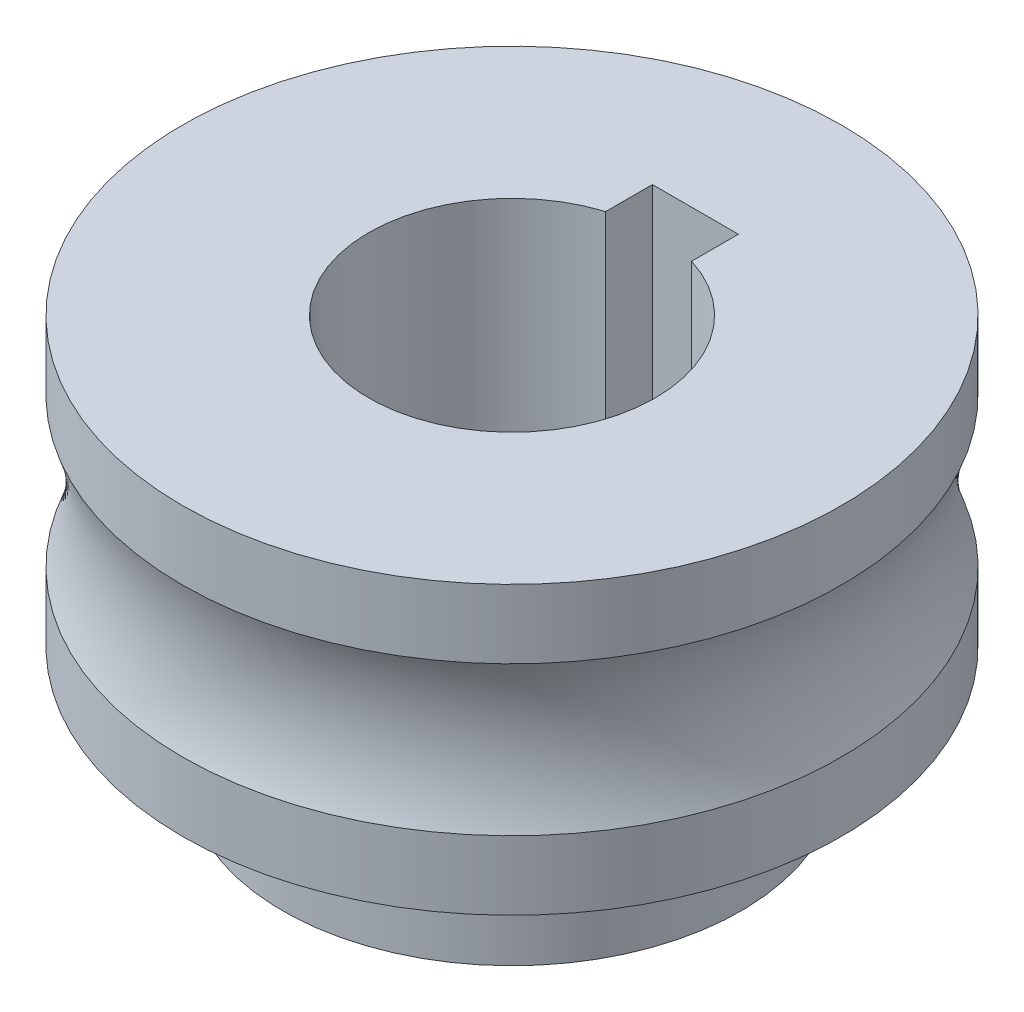
from build123d import *

# Parameters (mm, degrees)
ESQUISSE1_W             = 3
ESQUISSE1_H             = 2.8
ENL_V_MAT_EXTRU_1_DEPTH = 21
ESQUISSE2_R             = 8
ENL_V_MAT_EXTRU_2_DEPTH = 6


with BuildPart() as part:
    # Sketch1 → Revolve2 (revolve)
    with BuildSketch(Plane.XY):
        with BuildLine():
            Line((5, -15), (8, -15))
            Line((8, -15), (8, -5))
            Line((8, -5), (11.5, -5))
            Line((11.5, -5), (11.5, -2.598076211))
            ThreePointArc((11.5, -2.598076211), (11, 0), (11.5, 2.598076211))
            Line((11.5, 2.598076211), (11.5, 5))
            Line((11.5, 5), (5, 5))
            Line((5, 5), (5, -15))
        make_face()
    revolve(axis=Axis((0, -15, 0), (0, 1, 0)))

    # Esquisse1 → Enlèv. mat.-Extru.1 (cut, through all)
    with BuildSketch(Plane(origin=(0, 5, 0), x_dir=(1, 0, 0), z_dir=(0, 1, 0))):
        with Locations((0, 5)):
            Rectangle(ESQUISSE1_W, ESQUISSE1_H)
    extrude(amount=-ENL_V_MAT_EXTRU_1_DEPTH, mode=Mode.SUBTRACT)

    # Esquisse2 → Enlèv. mat.-Extru.2 (cut)
    with BuildSketch(Plane.XZ.offset(15)):
        Circle(ESQUISSE2_R)
    extrude(amount=-ENL_V_MAT_EXTRU_2_DEPTH, mode=Mode.SUBTRACT)


solid = part.part
